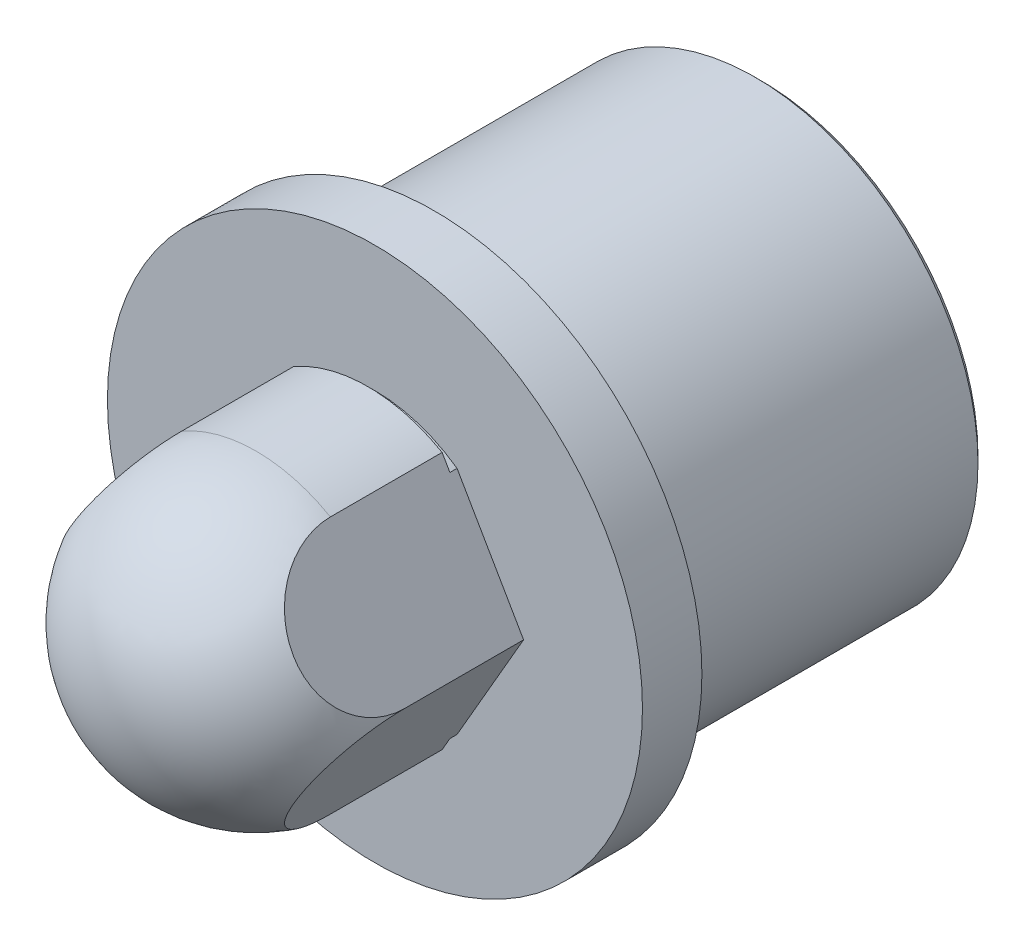
from build123d import *

# Parameters (mm, degrees)
SKETCH5_OUTSIDE_W   = 26.73
SKETCH5_OUTSIDE_H   = 26.73
CUT_EXTRUDE1_DEPTH  = 10
BOSS_EXTRUDE3_DEPTH = 0.24


with BuildPart() as part:
    # Sketch3 → Revolve1 (revolve)
    with BuildSketch(Plane(origin=(0, 0, 0), x_dir=(0, 0, -1), z_dir=(1, 0, 0))):
        with BuildLine():
            Line((-2, 5), (-2, 9))
            Line((-2, 9), (0, 9))
            Line((0, 9), (0, 7.5))
            Line((0, 7.5), (0, 7.26))
            Line((0, 7.26), (0.24, 7.26))
            Line((0.24, 7.26), (0.24, 7.5))
            Line((0.24, 7.5), (10.787867966, 7.5))
            Line((10.787867966, 7.5), (11, 7.287867966))
            Line((11, 7.287867966), (11, 0))
            Line((11, 0), (-11, 0))
            ThreePointArc((-11, 0), (-9.535533906, 3.535533906), (-6, 5))
            Line((-6, 5), (-2.24, 5))
            Line((-2.24, 5), (-2.24, 4.76))
            Line((-2.24, 4.76), (-2, 4.76))
            Line((-2, 4.76), (-2, 5))
        make_face()
    revolve(axis=Axis((0, 0, 11), (0, 0, -1)))

    # Sketch5 outside → Cut-Extrude1 (cut, through all)
    with BuildSketch(Plane.XY.offset(2)):
        Rectangle(SKETCH5_OUTSIDE_W, SKETCH5_OUTSIDE_H)
        with BuildLine():
            Line((-5, 0), (-2.5, -4.330127019))
            ThreePointArc((-2.5, -4.330127019), (0, -5), (2.5, -4.330127019))
            Line((2.5, -4.330127019), (5, 0))
            Line((5, 0), (2.5, 4.330127019))
            ThreePointArc((2.5, 4.330127019), (0, 5), (-2.5, 4.330127019))
            Line((-2.5, 4.330127019), (-5, 0))
        make_face(mode=Mode.SUBTRACT)
    extrude(amount=CUT_EXTRUDE1_DEPTH, mode=Mode.SUBTRACT)

    # Sketch7 → Boss-Extrude3 (add)
    with BuildSketch(Plane.XY.offset(2)):
        with BuildLine():
            Line((-4.738382517, -0.453134773), (-5, 0))
            Line((-5, 0), (-4.738382517, 0.453134773))
            ThreePointArc((-4.738382517, 0.453134773), (-4.76, 0), (-4.738382517, -0.453134773))
        make_face()
        with BuildLine():
            Line((4.738382517, 0.453134773), (5, 0))
            Line((5, 0), (4.738382517, -0.453134773))
            ThreePointArc((4.738382517, -0.453134773), (4.76, 0), (4.738382517, 0.453134773))
        make_face()
    extrude(amount=BOSS_EXTRUDE3_DEPTH)


solid = part.part
